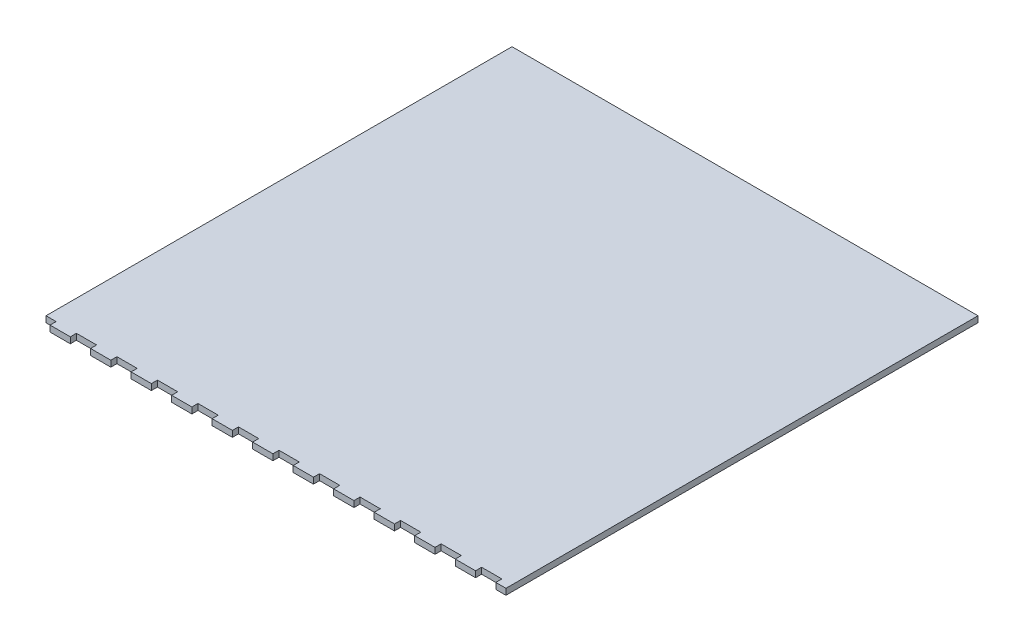
from build123d import *

# Parameters (mm, degrees)
ESQUISSE1_W             = 230
ESQUISSE1_H             = 233
BASE_DEPTH              = 3
ENL_V_MAT_EXTRU_1_REACH = 5
ESQUISSE2_W             = 10
ESQUISSE2_H             = 3


with BuildPart() as part:
    # Esquisse1 → Base (new body)
    with BuildSketch(Plane(origin=(0, 0, 0), x_dir=(1, 0, 0), z_dir=(0, 1, 0))):
        with Locations((115, 116.5)):
            Rectangle(ESQUISSE1_W, ESQUISSE1_H)
    extrude(amount=BASE_DEPTH)

    # Esquisse2 → Enlèv. mat.-Extru.1 (cut, up to next)
    with BuildSketch(Plane(origin=(0, 3, 0), x_dir=(1, 0, 0), z_dir=(0, 1, 0)), mode=Mode.PRIVATE) as enl_v_mat_extru_1_sk1:
        with Locations((120, 1.5)):
            Rectangle(ESQUISSE2_W, ESQUISSE2_H)
    enl_v_mat_extru_1_tool1 = extrude(enl_v_mat_extru_1_sk1.sketch, amount=-ENL_V_MAT_EXTRU_1_REACH, mode=Mode.PRIVATE) & part.part
    add(enl_v_mat_extru_1_tool1.solids().sort_by_distance((120, 3, -1.5))[0], mode=Mode.SUBTRACT)
    # Esquisse2 → Enlèv. mat.-Extru.1 (cut, up to next)
    with BuildSketch(Plane(origin=(0, 3, 0), x_dir=(1, 0, 0), z_dir=(0, 1, 0)), mode=Mode.PRIVATE) as enl_v_mat_extru_1_sk2:
        with Locations((140, 1.5)):
            Rectangle(ESQUISSE2_W, ESQUISSE2_H)
    enl_v_mat_extru_1_tool2 = extrude(enl_v_mat_extru_1_sk2.sketch, amount=-ENL_V_MAT_EXTRU_1_REACH, mode=Mode.PRIVATE) & part.part
    add(enl_v_mat_extru_1_tool2.solids().sort_by_distance((140, 3, -1.5))[0], mode=Mode.SUBTRACT)
    # Esquisse2 → Enlèv. mat.-Extru.1 (cut, up to next)
    with BuildSketch(Plane(origin=(0, 3, 0), x_dir=(1, 0, 0), z_dir=(0, 1, 0)), mode=Mode.PRIVATE) as enl_v_mat_extru_1_sk3:
        with Locations((160, 1.5)):
            Rectangle(ESQUISSE2_W, ESQUISSE2_H)
    enl_v_mat_extru_1_tool3 = extrude(enl_v_mat_extru_1_sk3.sketch, amount=-ENL_V_MAT_EXTRU_1_REACH, mode=Mode.PRIVATE) & part.part
    add(enl_v_mat_extru_1_tool3.solids().sort_by_distance((160, 3, -1.5))[0], mode=Mode.SUBTRACT)
    # Esquisse2 → Enlèv. mat.-Extru.1 (cut, up to next)
    with BuildSketch(Plane(origin=(0, 3, 0), x_dir=(1, 0, 0), z_dir=(0, 1, 0)), mode=Mode.PRIVATE) as enl_v_mat_extru_1_sk4:
        with Locations((180, 1.5)):
            Rectangle(ESQUISSE2_W, ESQUISSE2_H)
    enl_v_mat_extru_1_tool4 = extrude(enl_v_mat_extru_1_sk4.sketch, amount=-ENL_V_MAT_EXTRU_1_REACH, mode=Mode.PRIVATE) & part.part
    add(enl_v_mat_extru_1_tool4.solids().sort_by_distance((180, 3, -1.5))[0], mode=Mode.SUBTRACT)
    # Esquisse2 → Enlèv. mat.-Extru.1 (cut, up to next)
    with BuildSketch(Plane(origin=(0, 3, 0), x_dir=(1, 0, 0), z_dir=(0, 1, 0)), mode=Mode.PRIVATE) as enl_v_mat_extru_1_sk5:
        with Locations((200, 1.5)):
            Rectangle(ESQUISSE2_W, ESQUISSE2_H)
    enl_v_mat_extru_1_tool5 = extrude(enl_v_mat_extru_1_sk5.sketch, amount=-ENL_V_MAT_EXTRU_1_REACH, mode=Mode.PRIVATE) & part.part
    add(enl_v_mat_extru_1_tool5.solids().sort_by_distance((200, 3, -1.5))[0], mode=Mode.SUBTRACT)
    # Esquisse2 → Enlèv. mat.-Extru.1 (cut, up to next)
    with BuildSketch(Plane(origin=(0, 3, 0), x_dir=(1, 0, 0), z_dir=(0, 1, 0)), mode=Mode.PRIVATE) as enl_v_mat_extru_1_sk6:
        with Locations((220, 1.5)):
            Rectangle(ESQUISSE2_W, ESQUISSE2_H)
    enl_v_mat_extru_1_tool6 = extrude(enl_v_mat_extru_1_sk6.sketch, amount=-ENL_V_MAT_EXTRU_1_REACH, mode=Mode.PRIVATE) & part.part
    add(enl_v_mat_extru_1_tool6.solids().sort_by_distance((220, 3, -1.5))[0], mode=Mode.SUBTRACT)
    # Esquisse2 → Enlèv. mat.-Extru.1 (cut, up to next)
    with BuildSketch(Plane(origin=(0, 3, 0), x_dir=(1, 0, 0), z_dir=(0, 1, 0)), mode=Mode.PRIVATE) as enl_v_mat_extru_1_sk7:
        with Locations((100, 1.5)):
            Rectangle(ESQUISSE2_W, ESQUISSE2_H)
    enl_v_mat_extru_1_tool7 = extrude(enl_v_mat_extru_1_sk7.sketch, amount=-ENL_V_MAT_EXTRU_1_REACH, mode=Mode.PRIVATE) & part.part
    add(enl_v_mat_extru_1_tool7.solids().sort_by_distance((100, 3, -1.5))[0], mode=Mode.SUBTRACT)
    # Esquisse2 → Enlèv. mat.-Extru.1 (cut, up to next)
    with BuildSketch(Plane(origin=(0, 3, 0), x_dir=(1, 0, 0), z_dir=(0, 1, 0)), mode=Mode.PRIVATE) as enl_v_mat_extru_1_sk8:
        with Locations((80, 1.5)):
            Rectangle(ESQUISSE2_W, ESQUISSE2_H)
    enl_v_mat_extru_1_tool8 = extrude(enl_v_mat_extru_1_sk8.sketch, amount=-ENL_V_MAT_EXTRU_1_REACH, mode=Mode.PRIVATE) & part.part
    add(enl_v_mat_extru_1_tool8.solids().sort_by_distance((80, 3, -1.5))[0], mode=Mode.SUBTRACT)
    # Esquisse2 → Enlèv. mat.-Extru.1 (cut, up to next)
    with BuildSketch(Plane(origin=(0, 3, 0), x_dir=(1, 0, 0), z_dir=(0, 1, 0)), mode=Mode.PRIVATE) as enl_v_mat_extru_1_sk9:
        with Locations((60, 1.5)):
            Rectangle(ESQUISSE2_W, ESQUISSE2_H)
    enl_v_mat_extru_1_tool9 = extrude(enl_v_mat_extru_1_sk9.sketch, amount=-ENL_V_MAT_EXTRU_1_REACH, mode=Mode.PRIVATE) & part.part
    add(enl_v_mat_extru_1_tool9.solids().sort_by_distance((60, 3, -1.5))[0], mode=Mode.SUBTRACT)
    # Esquisse2 → Enlèv. mat.-Extru.1 (cut, up to next)
    with BuildSketch(Plane(origin=(0, 3, 0), x_dir=(1, 0, 0), z_dir=(0, 1, 0)), mode=Mode.PRIVATE) as enl_v_mat_extru_1_sk10:
        with Locations((40, 1.5)):
            Rectangle(ESQUISSE2_W, ESQUISSE2_H)
    enl_v_mat_extru_1_tool10 = extrude(enl_v_mat_extru_1_sk10.sketch, amount=-ENL_V_MAT_EXTRU_1_REACH, mode=Mode.PRIVATE) & part.part
    add(enl_v_mat_extru_1_tool10.solids().sort_by_distance((40, 3, -1.5))[0], mode=Mode.SUBTRACT)
    # Esquisse2 → Enlèv. mat.-Extru.1 (cut, up to next)
    with BuildSketch(Plane(origin=(0, 3, 0), x_dir=(1, 0, 0), z_dir=(0, 1, 0)), mode=Mode.PRIVATE) as enl_v_mat_extru_1_sk11:
        with Locations((20, 1.5)):
            Rectangle(ESQUISSE2_W, ESQUISSE2_H)
    enl_v_mat_extru_1_tool11 = extrude(enl_v_mat_extru_1_sk11.sketch, amount=-ENL_V_MAT_EXTRU_1_REACH, mode=Mode.PRIVATE) & part.part
    add(enl_v_mat_extru_1_tool11.solids().sort_by_distance((20, 3, -1.5))[0], mode=Mode.SUBTRACT)
    # Esquisse2 → Enlèv. mat.-Extru.1 (cut, up to next)
    with BuildSketch(Plane(origin=(0, 3, 0), x_dir=(1, 0, 0), z_dir=(0, 1, 0)), mode=Mode.PRIVATE) as enl_v_mat_extru_1_sk12:
        with Locations((0, 1.5)):
            Rectangle(ESQUISSE2_W, ESQUISSE2_H)
    enl_v_mat_extru_1_tool12 = extrude(enl_v_mat_extru_1_sk12.sketch, amount=-ENL_V_MAT_EXTRU_1_REACH, mode=Mode.PRIVATE) & part.part
    add(enl_v_mat_extru_1_tool12.solids().sort_by_distance((0, 3, -1.5))[0], mode=Mode.SUBTRACT)


solid = part.part
